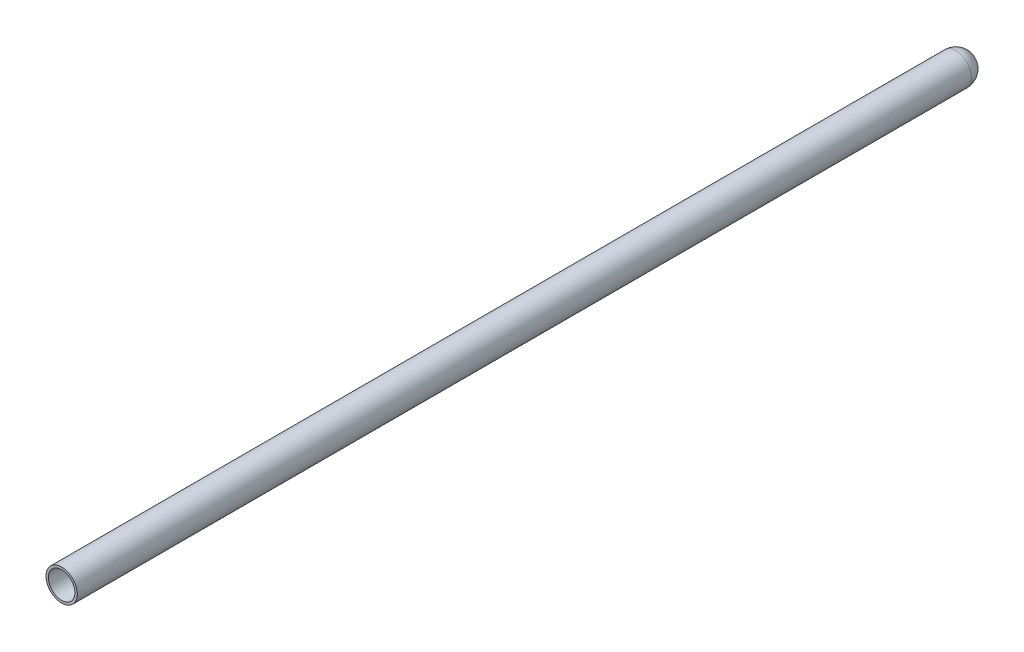
from build123d import *


with BuildPart() as part:
    # Sketch2 → Revolve1 (revolve)
    with BuildSketch(Plane(origin=(0, 0, 0), x_dir=(1, 0, 0), z_dir=(0, 1, 0))):
        with BuildLine():
            Line((2.2, -84.6), (2.2, 63.8))
            ThreePointArc((2.2, 63.8), (1.555634919, 65.355634919), (0, 66))
            Line((0, 66), (0, 66.4))
            ThreePointArc((0, 66.4), (1.838477631, 65.638477631), (2.6, 63.8))
            Line((2.6, 63.8), (2.6, -84.6))
            Line((2.6, -84.6), (2.2, -84.6))
        make_face()
    revolve(axis=Axis((0, 0, 0), (0, 0, -1)))


solid = part.part
